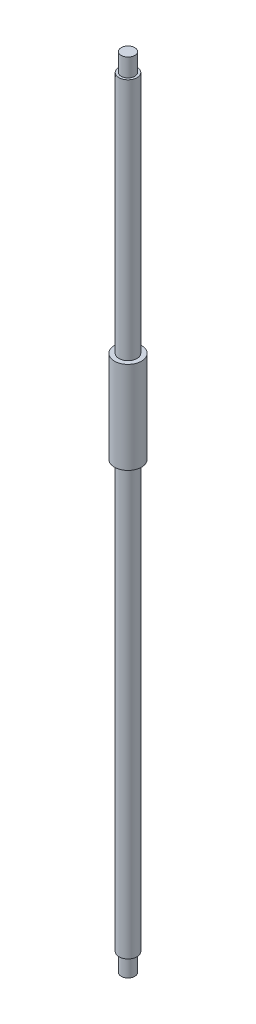
from build123d import *

# Parameters (mm, degrees)
SKETCH1_R           = 12.7
BOSS_EXTRUDE1_DEPTH = 1120
SKETCH3_R           = 12.7
SKETCH3_R_2         = 9.525
CUT_EXTRUDE1_DEPTH  = 25.4
SKETCH4_R           = 12.7
SKETCH4_R_2         = 9.525
CUT_EXTRUDE2_DEPTH  = 25.4
SKETCH5_R           = 19.05
SKETCH5_R_2         = 12.7
BOSS_EXTRUDE2_DEPTH = 129


with BuildPart() as part:
    # Sketch1 → Boss-Extrude1 (new body)
    with BuildSketch(Plane(origin=(0, 0, 0), x_dir=(1, 0, 0), z_dir=(0, 1, 0))):
        Circle(SKETCH1_R)
    extrude(amount=BOSS_EXTRUDE1_DEPTH)

    # Sketch3 → Cut-Extrude1 (cut)
    with BuildSketch(Plane.XZ):
        Circle(SKETCH3_R)
        Circle(SKETCH3_R_2, mode=Mode.SUBTRACT)
    extrude(amount=-CUT_EXTRUDE1_DEPTH, mode=Mode.SUBTRACT)

    # Sketch4 → Cut-Extrude2 (cut)
    with BuildSketch(Plane(origin=(0, 1120, 0), x_dir=(1, 0, 0), z_dir=(0, 1, 0))):
        Circle(SKETCH4_R)
        Circle(SKETCH4_R_2, mode=Mode.SUBTRACT)
    extrude(amount=-CUT_EXTRUDE2_DEPTH, mode=Mode.SUBTRACT)

    # Sketch5 → Boss-Extrude2 (add)
    with BuildSketch(Plane(origin=(0, 753, 0), x_dir=(1, 0, 0), z_dir=(0, 1, 0))):
        Circle(SKETCH5_R)
        Circle(SKETCH5_R_2, mode=Mode.SUBTRACT)
    extrude(amount=-BOSS_EXTRUDE2_DEPTH)


solid = part.part
